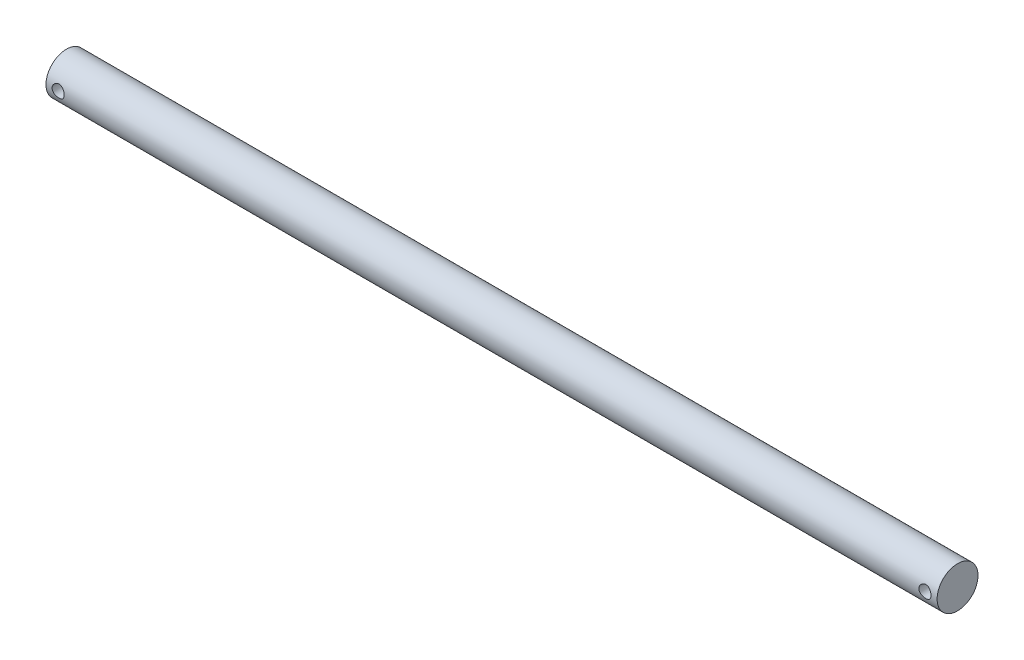
from build123d import *

# Parameters (mm, degrees)
CROQUIS1_R                        = 5.05
SALIENTE_EXTRUIR1_DEPTH           = 220
CORTAR_EXTRUIR1_REACH             = 7.05
CROQUIS2_R                        = 1.5
CORTAR_EXTRUIR1_DIRECTION_2_REACH = 7.05


with BuildPart() as part:
    # Croquis1 → Saliente-Extruir1 (new body)
    with BuildSketch(Plane(origin=(0, 0, 0), x_dir=(0, 0, -1), z_dir=(1, 0, 0))):
        Circle(CROQUIS1_R)
    extrude(amount=SALIENTE_EXTRUIR1_DEPTH)

    # Croquis2 → Cortar-Extruir1 (cut, up to next)
    with BuildSketch(Plane.XY, mode=Mode.PRIVATE) as cortar_extruir1_sk1:
        with Locations((3, 0)):
            Circle(CROQUIS2_R)
    cortar_extruir1_tool1 = extrude(cortar_extruir1_sk1.sketch, amount=-CORTAR_EXTRUIR1_REACH, mode=Mode.PRIVATE) & part.part
    add(cortar_extruir1_tool1.solids().sort_by_distance((3, 0, 0))[0], mode=Mode.SUBTRACT)
    # Croquis2 → Cortar-Extruir1 (cut, up to next)
    with BuildSketch(Plane.XY, mode=Mode.PRIVATE) as cortar_extruir1_sk2:
        with Locations((217, 0)):
            Circle(CROQUIS2_R)
    cortar_extruir1_tool2 = extrude(cortar_extruir1_sk2.sketch, amount=-CORTAR_EXTRUIR1_REACH, mode=Mode.PRIVATE) & part.part
    add(cortar_extruir1_tool2.solids().sort_by_distance((217, 0, 0))[0], mode=Mode.SUBTRACT)

    # Croquis2 → Cortar-Extruir1 direction 2 (cut, up to next)
    with BuildSketch(Plane.XY, mode=Mode.PRIVATE) as cortar_extruir1_direction_2_sk1:
        with Locations((3, 0)):
            Circle(CROQUIS2_R)
    cortar_extruir1_direction_2_tool1 = extrude(cortar_extruir1_direction_2_sk1.sketch, amount=CORTAR_EXTRUIR1_DIRECTION_2_REACH, mode=Mode.PRIVATE) & part.part
    add(cortar_extruir1_direction_2_tool1.solids().sort_by_distance((3, 0, 0))[0], mode=Mode.SUBTRACT)
    # Croquis2 → Cortar-Extruir1 direction 2 (cut, up to next)
    with BuildSketch(Plane.XY, mode=Mode.PRIVATE) as cortar_extruir1_direction_2_sk2:
        with Locations((217, 0)):
            Circle(CROQUIS2_R)
    cortar_extruir1_direction_2_tool2 = extrude(cortar_extruir1_direction_2_sk2.sketch, amount=CORTAR_EXTRUIR1_DIRECTION_2_REACH, mode=Mode.PRIVATE) & part.part
    add(cortar_extruir1_direction_2_tool2.solids().sort_by_distance((217, 0, 0))[0], mode=Mode.SUBTRACT)


solid = part.part
